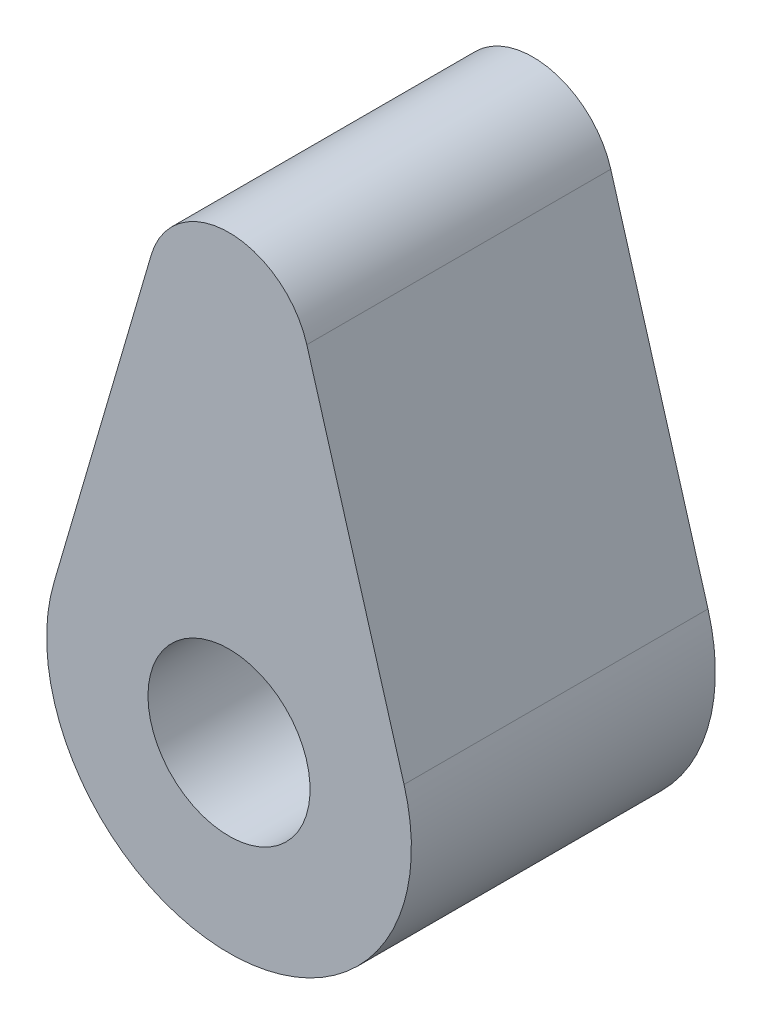
from build123d import *

# Parameters (mm, degrees)
EXTRUDE_1_DEPTH     = 15
SKETCH_2_R          = 4
CUT_EXTRUDE_1_DEPTH = 4
SKETCH_2_3_R        = 4
CUT_EXTRUDE_2_DEPTH = 28.950670833


with BuildPart() as part:
    # Эскиз1 → Бобышка-Вытянуть1 (new body)
    with BuildSketch(Plane.XY):
        with BuildLine():
            Line((8.637636339, 2.528089888), (3.838949484, 18.923595506))
            ThreePointArc((3.838949484, 18.923595506), (0, 21.8), (-3.838949484, 18.923595506))
            Line((-3.838949484, 18.923595506), (-8.637636339, 2.528089888))
            ThreePointArc((-8.637636339, 2.528089888), (0, -9), (8.637636339, 2.528089888))
        make_face()
    extrude(amount=EXTRUDE_1_DEPTH)

    # Эскиз2 → Вырез-Вытянуть1 (cut)
    with BuildSketch(Plane(origin=(0, 0, 0), x_dir=(-1, 0, 0), z_dir=(0, 0, -1))):
        with BuildLine():
            Line((4.737753812, 4.302753632), (2.6, 17.8))
            ThreePointArc((2.6, 17.8), (0, 20.4), (-2.6, 17.8))
            Line((-2.6, 17.8), (-4.737753812, 4.302753632))
            ThreePointArc((-4.737753812, 4.302753632), (0, -6.4), (4.737753812, 4.302753632))
        make_face()
        Circle(SKETCH_2_R, mode=Mode.SUBTRACT)
    extrude(amount=-CUT_EXTRUDE_1_DEPTH, mode=Mode.SUBTRACT)

    # Эскиз2<3> → Вырез-Вытянуть2 (cut, through all)
    with BuildSketch(Plane(origin=(0, 0, 0), x_dir=(-1, 0, 0), z_dir=(0, 0, -1))):
        Circle(SKETCH_2_3_R)
    extrude(amount=-CUT_EXTRUDE_2_DEPTH, mode=Mode.SUBTRACT)


solid = part.part
